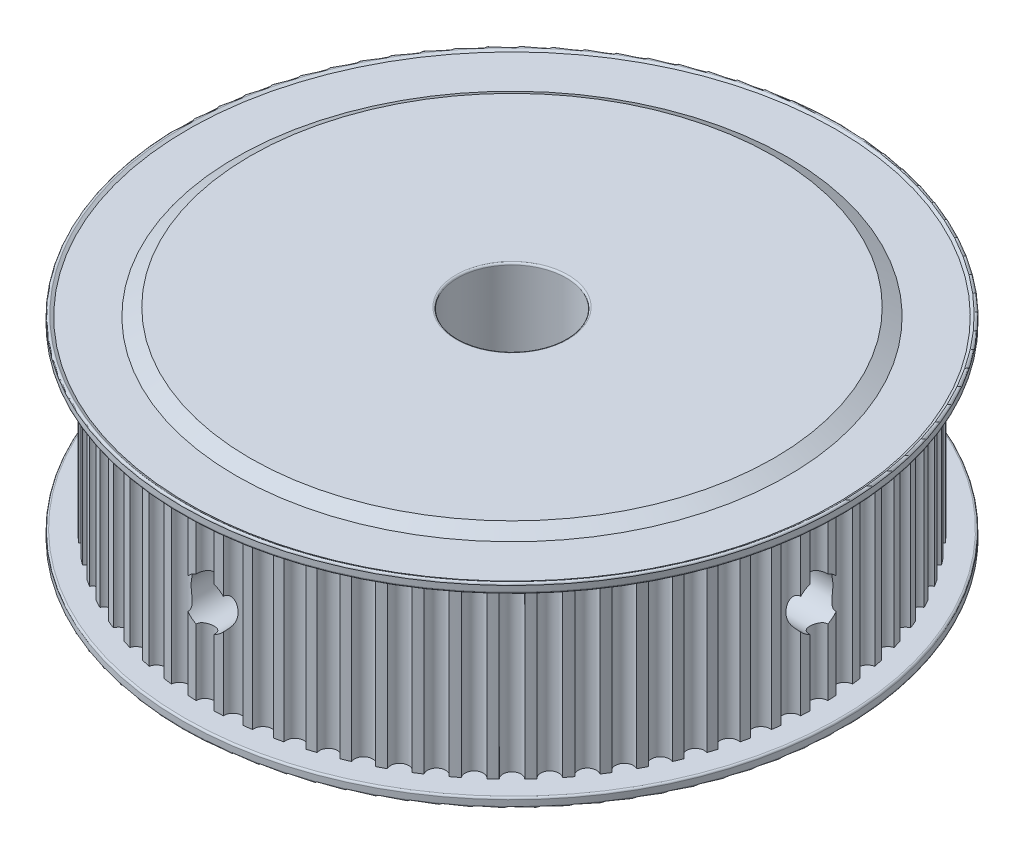
from build123d import *

# Parameters (mm, degrees)
FILLET1_R            = 0.2
BOSS_EXTRUDE1_DEPTH  = 19.5
FILLET1_OF_MIRROR1_R = 0.2
SKETCH4_R            = 2.6
CUT_EXTRUDE1_DEPTH   = 36.5
SKETCH5_R            = 2.6
CUT_EXTRUDE2_DEPTH   = 36.5
SKETCH3_R            = 6
CUT_EXTRUDE3_DEPTH   = 24
FILLET2_R            = 0.2
SCALE2_SCALE         = 0.2
SCALE4_SCALE         = 2


with BuildPart() as part:
    # Sketch1 → Revolve1 (revolve)
    with BuildSketch(Plane.XY):
        Polygon((0, 0), (0, 1.75), (36.5, 1.75), (36.5, 0.55), (35.893782217, 0.9), (30.558845727, 0.9), (29, 0), align=None)
    revolve1 = revolve(axis=Axis((0, 0, 0), (0, 1, 0)))

    # Fillet1
    fillet1_edges = [part.edges().sort_by_distance(p)[0] for p in [
        (-36.5, 0.55, 0),
        (-36.5, 1.75, 0),
    ]]
    fillet(fillet1_edges, radius=FILLET1_R)

    # Sketch2 → Boss-Extrude1 (add)
    with BuildSketch(Plane(origin=(0, 1.75, 0), x_dir=(1, 0, 0), z_dir=(0, 1, 0))):
        with BuildLine():
            ThreePointArc((1.965926579, 33.943116131), (1.48305917, 33.967639534), (0.999891863, 33.985294118))
            ThreePointArc((0.999891863, 33.985294118), (0, 33), (-0.999891863, 33.985294118))
            ThreePointArc((-0.999891863, 33.985294118), (-1.48305917, 33.967639534), (-1.965926579, 33.943116131))
            ThreePointArc((-1.965926579, 33.943116131), (-2.876139511, 32.874425037), (-3.958100524, 33.768823495))
            ThreePointArc((-3.958100524, 33.768823495), (-4.437890535, 33.709125287), (-4.916783132, 33.642610535))
            ThreePointArc((-4.916783132, 33.642610535), (-5.730389863, 32.498655849), (-6.88618565, 33.295351736))
            ThreePointArc((-6.88618565, 33.295351736), (-7.358946874, 33.194064242), (-7.830219997, 33.086064359))
            ThreePointArc((-7.830219997, 33.086064359), (-8.541028488, 31.875552268), (-9.761862745, 32.568482245))
            ThreePointArc((-9.761862745, 32.568482245), (-10.223997183, 32.426376325), (-10.68406416, 32.277713256))
            ThreePointArc((-10.68406416, 32.277713256), (-11.28666473, 31.009856486), (-12.56324617, 31.593746939))
            ThreePointArc((-12.56324617, 31.593746939), (-13.0112367, 31.411904105), (-13.456596143, 31.223709264))
            ThreePointArc((-13.456596143, 31.223709264), (-13.946402637, 29.908156972), (-15.269015706, 30.378564143))
            ThreePointArc((-15.269015706, 30.378564143), (-15.69945285, 30.158368328), (-16.126715305, 29.932073992))
            ThreePointArc((-16.126715305, 29.932073992), (-16.5, 28.578838325), (-17.858578813, 28.93218213))
            ThreePointArc((-17.858578813, 28.93218213), (-18.268186684, 28.675309158), (-18.674100425, 28.412637564))
            ThreePointArc((-18.674100425, 28.412637564), (-18.9280224, 27.032017462), (-20.312227352, 27.265608741))
            ThreePointArc((-20.312227352, 27.265608741), (-20.697888586, 26.97401357), (-21.079364365, 26.676963807))
            ThreePointArc((-21.079364365, 26.676963807), (-21.21199112, 25.279466623), (-22.611287575, 25.391527606))
            ThreePointArc((-22.611287575, 25.391527606), (-22.970067059, 25.067429452), (-23.324201615, 24.738262248))
            ThreePointArc((-23.324201615, 24.738262248), (-23.334523779, 23.334523779), (-24.738262248, 23.324201615))
            ThreePointArc((-24.738262248, 23.324201615), (-25.067429452, 22.970067059), (-25.391527606, 22.611287575))
            ThreePointArc((-25.391527606, 22.611287575), (-25.279466623, 21.21199112), (-26.676963807, 21.079364365))
            ThreePointArc((-26.676963807, 21.079364365), (-26.97401357, 20.697888586), (-27.265608741, 20.312227352))
            ThreePointArc((-27.265608741, 20.312227352), (-27.032017462, 18.9280224), (-28.412637564, 18.674100425))
            ThreePointArc((-28.412637564, 18.674100425), (-28.675309158, 18.268186684), (-28.93218213, 17.858578813))
            ThreePointArc((-28.93218213, 17.858578813), (-28.578838325, 16.5), (-29.932073992, 16.126715305))
            ThreePointArc((-29.932073992, 16.126715305), (-30.158368328, 15.69945285), (-30.378564143, 15.269015706))
            ThreePointArc((-30.378564143, 15.269015706), (-29.908156972, 13.946402637), (-31.223709264, 13.456596143))
            ThreePointArc((-31.223709264, 13.456596143), (-31.411904105, 13.0112367), (-31.593746939, 12.56324617))
            ThreePointArc((-31.593746939, 12.56324617), (-31.009856486, 11.28666473), (-32.277713256, 10.68406416))
            ThreePointArc((-32.277713256, 10.68406416), (-32.426376325, 10.223997183), (-32.568482245, 9.761862745))
            ThreePointArc((-32.568482245, 9.761862745), (-31.875552268, 8.541028488), (-33.086064359, 7.830219997))
            ThreePointArc((-33.086064359, 7.830219997), (-33.194064242, 7.358946874), (-33.295351736, 6.88618565))
            ThreePointArc((-33.295351736, 6.88618565), (-32.498655849, 5.730389863), (-33.642610535, 4.916783132))
            ThreePointArc((-33.642610535, 4.916783132), (-33.709125287, 4.437890535), (-33.768823495, 3.958100524))
            ThreePointArc((-33.768823495, 3.958100524), (-32.874425037, 2.876139511), (-33.943116131, 1.965926579))
            ThreePointArc((-33.943116131, 1.965926579), (-33.967639534, 1.48305917), (-33.985294118, 0.999891863))
            ThreePointArc((-33.985294118, 0.999891863), (-33, 0), (-33.985294118, -0.999891863))
            ThreePointArc((-33.985294118, -0.999891863), (-33.967639534, -1.48305917), (-33.943116131, -1.965926579))
            ThreePointArc((-33.943116131, -1.965926579), (-32.874425037, -2.876139511), (-33.768823495, -3.958100524))
            ThreePointArc((-33.768823495, -3.958100524), (-33.709125287, -4.437890535), (-33.642610535, -4.916783132))
            ThreePointArc((-33.642610535, -4.916783132), (-32.498655849, -5.730389863), (-33.295351736, -6.88618565))
            ThreePointArc((-33.295351736, -6.88618565), (-33.194064242, -7.358946874), (-33.086064359, -7.830219997))
            ThreePointArc((-33.086064359, -7.830219997), (-31.875552268, -8.541028488), (-32.568482245, -9.761862745))
            ThreePointArc((-32.568482245, -9.761862745), (-32.426376325, -10.223997183), (-32.277713256, -10.68406416))
            ThreePointArc((-32.277713256, -10.68406416), (-31.009856486, -11.28666473), (-31.593746939, -12.56324617))
            ThreePointArc((-31.593746939, -12.56324617), (-31.411904105, -13.0112367), (-31.223709264, -13.456596143))
            ThreePointArc((-31.223709264, -13.456596143), (-29.908156972, -13.946402637), (-30.378564143, -15.269015706))
            ThreePointArc((-30.378564143, -15.269015706), (-30.158368328, -15.69945285), (-29.932073992, -16.126715305))
            ThreePointArc((-29.932073992, -16.126715305), (-28.578838325, -16.5), (-28.93218213, -17.858578813))
            ThreePointArc((-28.93218213, -17.858578813), (-28.675309158, -18.268186684), (-28.412637564, -18.674100425))
            ThreePointArc((-28.412637564, -18.674100425), (-27.032017462, -18.9280224), (-27.265608741, -20.312227352))
            ThreePointArc((-27.265608741, -20.312227352), (-26.97401357, -20.697888586), (-26.676963807, -21.079364365))
            ThreePointArc((-26.676963807, -21.079364365), (-25.279466623, -21.21199112), (-25.391527606, -22.611287575))
            ThreePointArc((-25.391527606, -22.611287575), (-25.067429452, -22.970067059), (-24.738262248, -23.324201615))
            ThreePointArc((-24.738262248, -23.324201615), (-23.334523779, -23.334523779), (-23.324201615, -24.738262248))
            ThreePointArc((-23.324201615, -24.738262248), (-22.970067059, -25.067429452), (-22.611287575, -25.391527606))
            ThreePointArc((-22.611287575, -25.391527606), (-21.21199112, -25.279466623), (-21.079364365, -26.676963807))
            ThreePointArc((-21.079364365, -26.676963807), (-20.697888586, -26.97401357), (-20.312227352, -27.265608741))
            ThreePointArc((-20.312227352, -27.265608741), (-18.9280224, -27.032017462), (-18.674100425, -28.412637564))
            ThreePointArc((-18.674100425, -28.412637564), (-18.268186684, -28.675309158), (-17.858578813, -28.93218213))
            ThreePointArc((-17.858578813, -28.93218213), (-16.5, -28.578838325), (-16.126715305, -29.932073992))
            ThreePointArc((-16.126715305, -29.932073992), (-15.69945285, -30.158368328), (-15.269015706, -30.378564143))
            ThreePointArc((-15.269015706, -30.378564143), (-13.946402637, -29.908156972), (-13.456596143, -31.223709264))
            ThreePointArc((-13.456596143, -31.223709264), (-13.0112367, -31.411904105), (-12.56324617, -31.593746939))
            ThreePointArc((-12.56324617, -31.593746939), (-11.28666473, -31.009856486), (-10.68406416, -32.277713256))
            ThreePointArc((-10.68406416, -32.277713256), (-10.223997183, -32.426376325), (-9.761862745, -32.568482245))
            ThreePointArc((-9.761862745, -32.568482245), (-8.541028488, -31.875552268), (-7.830219997, -33.086064359))
            ThreePointArc((-7.830219997, -33.086064359), (-7.358946874, -33.194064242), (-6.88618565, -33.295351736))
            ThreePointArc((-6.88618565, -33.295351736), (-5.730389863, -32.498655849), (-4.916783132, -33.642610535))
            ThreePointArc((-4.916783132, -33.642610535), (-4.437890535, -33.709125287), (-3.958100524, -33.768823495))
            ThreePointArc((-3.958100524, -33.768823495), (-2.876139511, -32.874425037), (-1.965926579, -33.943116131))
            ThreePointArc((-1.965926579, -33.943116131), (-1.48305917, -33.967639534), (-0.999891863, -33.985294118))
            ThreePointArc((-0.999891863, -33.985294118), (0, -33), (0.999891863, -33.985294118))
            ThreePointArc((0.999891863, -33.985294118), (1.48305917, -33.967639534), (1.965926579, -33.943116131))
            ThreePointArc((1.965926579, -33.943116131), (2.876139511, -32.874425037), (3.958100524, -33.768823495))
            ThreePointArc((3.958100524, -33.768823495), (4.437890535, -33.709125287), (4.916783132, -33.642610535))
            ThreePointArc((4.916783132, -33.642610535), (5.730389863, -32.498655849), (6.88618565, -33.295351736))
            ThreePointArc((6.88618565, -33.295351736), (7.358946874, -33.194064242), (7.830219997, -33.086064359))
            ThreePointArc((7.830219997, -33.086064359), (8.541028488, -31.875552268), (9.761862745, -32.568482245))
            ThreePointArc((9.761862745, -32.568482245), (10.223997183, -32.426376325), (10.68406416, -32.277713256))
            ThreePointArc((10.68406416, -32.277713256), (11.28666473, -31.009856486), (12.56324617, -31.593746939))
            ThreePointArc((12.56324617, -31.593746939), (13.0112367, -31.411904105), (13.456596143, -31.223709264))
            ThreePointArc((13.456596143, -31.223709264), (13.946402637, -29.908156972), (15.269015706, -30.378564143))
            ThreePointArc((15.269015706, -30.378564143), (15.69945285, -30.158368328), (16.126715305, -29.932073992))
            ThreePointArc((16.126715305, -29.932073992), (16.5, -28.578838325), (17.858578813, -28.93218213))
            ThreePointArc((17.858578813, -28.93218213), (18.268186684, -28.675309158), (18.674100425, -28.412637564))
            ThreePointArc((18.674100425, -28.412637564), (18.9280224, -27.032017462), (20.312227352, -27.265608741))
            ThreePointArc((20.312227352, -27.265608741), (20.697888586, -26.97401357), (21.079364365, -26.676963807))
            ThreePointArc((21.079364365, -26.676963807), (21.21199112, -25.279466623), (22.611287575, -25.391527606))
            ThreePointArc((22.611287575, -25.391527606), (22.970067059, -25.067429452), (23.324201615, -24.738262248))
            ThreePointArc((23.324201615, -24.738262248), (23.334523779, -23.334523779), (24.738262248, -23.324201615))
            ThreePointArc((24.738262248, -23.324201615), (25.067429452, -22.970067059), (25.391527606, -22.611287575))
            ThreePointArc((25.391527606, -22.611287575), (25.279466623, -21.21199112), (26.676963807, -21.079364365))
            ThreePointArc((26.676963807, -21.079364365), (26.97401357, -20.697888586), (27.265608741, -20.312227352))
            ThreePointArc((27.265608741, -20.312227352), (27.032017462, -18.9280224), (28.412637564, -18.674100425))
            ThreePointArc((28.412637564, -18.674100425), (28.675309158, -18.268186684), (28.93218213, -17.858578813))
            ThreePointArc((28.93218213, -17.858578813), (28.578838325, -16.5), (29.932073992, -16.126715305))
            ThreePointArc((29.932073992, -16.126715305), (30.158368328, -15.69945285), (30.378564143, -15.269015706))
            ThreePointArc((30.378564143, -15.269015706), (29.908156972, -13.946402637), (31.223709264, -13.456596143))
            ThreePointArc((31.223709264, -13.456596143), (31.411904105, -13.0112367), (31.593746939, -12.56324617))
            ThreePointArc((31.593746939, -12.56324617), (31.009856486, -11.28666473), (32.277713256, -10.68406416))
            ThreePointArc((32.277713256, -10.68406416), (32.426376325, -10.223997183), (32.568482245, -9.761862745))
            ThreePointArc((32.568482245, -9.761862745), (31.875552268, -8.541028488), (33.086064359, -7.830219997))
            ThreePointArc((33.086064359, -7.830219997), (33.194064242, -7.358946874), (33.295351736, -6.88618565))
            ThreePointArc((33.295351736, -6.88618565), (32.498655849, -5.730389863), (33.642610535, -4.916783132))
            ThreePointArc((33.642610535, -4.916783132), (33.709125287, -4.437890535), (33.768823495, -3.958100524))
            ThreePointArc((33.768823495, -3.958100524), (32.874425037, -2.876139511), (33.943116131, -1.965926579))
            ThreePointArc((33.943116131, -1.965926579), (33.967639534, -1.48305917), (33.985294118, -0.999891863))
            ThreePointArc((33.985294118, -0.999891863), (33, 0), (33.985294118, 0.999891863))
            ThreePointArc((33.985294118, 0.999891863), (33.967639534, 1.48305917), (33.943116131, 1.965926579))
            ThreePointArc((33.943116131, 1.965926579), (32.874425037, 2.876139511), (33.768823495, 3.958100524))
            ThreePointArc((33.768823495, 3.958100524), (33.709125287, 4.437890535), (33.642610535, 4.916783132))
            ThreePointArc((33.642610535, 4.916783132), (32.498655849, 5.730389863), (33.295351736, 6.88618565))
            ThreePointArc((33.295351736, 6.88618565), (33.194064242, 7.358946874), (33.086064359, 7.830219997))
            ThreePointArc((33.086064359, 7.830219997), (31.875552268, 8.541028488), (32.568482245, 9.761862745))
            ThreePointArc((32.568482245, 9.761862745), (32.426376325, 10.223997183), (32.277713256, 10.68406416))
            ThreePointArc((32.277713256, 10.68406416), (31.009856486, 11.28666473), (31.593746939, 12.56324617))
            ThreePointArc((31.593746939, 12.56324617), (31.411904105, 13.0112367), (31.223709264, 13.456596143))
            ThreePointArc((31.223709264, 13.456596143), (29.908156972, 13.946402637), (30.378564143, 15.269015706))
            ThreePointArc((30.378564143, 15.269015706), (30.158368328, 15.69945285), (29.932073992, 16.126715305))
            ThreePointArc((29.932073992, 16.126715305), (28.578838325, 16.5), (28.93218213, 17.858578813))
            ThreePointArc((28.93218213, 17.858578813), (28.675309158, 18.268186684), (28.412637564, 18.674100425))
            ThreePointArc((28.412637564, 18.674100425), (27.032017462, 18.9280224), (27.265608741, 20.312227352))
            ThreePointArc((27.265608741, 20.312227352), (26.97401357, 20.697888586), (26.676963807, 21.079364365))
            ThreePointArc((26.676963807, 21.079364365), (25.279466623, 21.21199112), (25.391527606, 22.611287575))
            ThreePointArc((25.391527606, 22.611287575), (25.067429452, 22.970067059), (24.738262248, 23.324201615))
            ThreePointArc((24.738262248, 23.324201615), (23.334523779, 23.334523779), (23.324201615, 24.738262248))
            ThreePointArc((23.324201615, 24.738262248), (22.970067059, 25.067429452), (22.611287575, 25.391527606))
            ThreePointArc((22.611287575, 25.391527606), (21.21199112, 25.279466623), (21.079364365, 26.676963807))
            ThreePointArc((21.079364365, 26.676963807), (20.697888586, 26.97401357), (20.312227352, 27.265608741))
            ThreePointArc((20.312227352, 27.265608741), (18.9280224, 27.032017462), (18.674100425, 28.412637564))
            ThreePointArc((18.674100425, 28.412637564), (18.268186684, 28.675309158), (17.858578813, 28.93218213))
            ThreePointArc((17.858578813, 28.93218213), (16.5, 28.578838325), (16.126715305, 29.932073992))
            ThreePointArc((16.126715305, 29.932073992), (15.69945285, 30.158368328), (15.269015706, 30.378564143))
            ThreePointArc((15.269015706, 30.378564143), (13.946402637, 29.908156972), (13.456596143, 31.223709264))
            ThreePointArc((13.456596143, 31.223709264), (13.0112367, 31.411904105), (12.56324617, 31.593746939))
            ThreePointArc((12.56324617, 31.593746939), (11.28666473, 31.009856486), (10.68406416, 32.277713256))
            ThreePointArc((10.68406416, 32.277713256), (10.223997183, 32.426376325), (9.761862745, 32.568482245))
            ThreePointArc((9.761862745, 32.568482245), (8.541028488, 31.875552268), (7.830219997, 33.086064359))
            ThreePointArc((7.830219997, 33.086064359), (7.358946874, 33.194064242), (6.88618565, 33.295351736))
            ThreePointArc((6.88618565, 33.295351736), (5.730389863, 32.498655849), (4.916783132, 33.642610535))
            ThreePointArc((4.916783132, 33.642610535), (4.437890535, 33.709125287), (3.958100524, 33.768823495))
            ThreePointArc((3.958100524, 33.768823495), (2.876139511, 32.874425037), (1.965926579, 33.943116131))
        make_face()
    extrude(amount=BOSS_EXTRUDE1_DEPTH)

    # Mirror1: Revolve1 across plane
    add(revolve1.mirror(Plane.ZX.offset(11.5)))

    # Fillet1 of Mirror1
    fillet1_of_mirror1_edges = [part.edges().sort_by_distance(p)[0] for p in [
        (-36.5, 22.45, 0),
        (-36.5, 21.25, 0),
    ]]
    fillet(fillet1_of_mirror1_edges, radius=FILLET1_OF_MIRROR1_R)

    # Sketch4 → Cut-Extrude1 (cut)
    with BuildSketch(Plane.XY):
        with Locations((0, 11.5)):
            Circle(SKETCH4_R)
    extrude(amount=CUT_EXTRUDE1_DEPTH, mode=Mode.SUBTRACT)

    # Sketch5 → Cut-Extrude2 (cut)
    with BuildSketch(Plane(origin=(0, 0, 0), x_dir=(0, 0, -1), z_dir=(1, 0, 0))):
        with Locations((0, 11.5)):
            Circle(SKETCH5_R)
    extrude(amount=CUT_EXTRUDE2_DEPTH, mode=Mode.SUBTRACT)

    # Sketch3 → Cut-Extrude3 (cut, through all)
    with BuildSketch(Plane(origin=(0, 23, 0), x_dir=(1, 0, 0), z_dir=(0, 1, 0))):
        Circle(SKETCH3_R)
    extrude(amount=-CUT_EXTRUDE3_DEPTH, mode=Mode.SUBTRACT)

    # Fillet2
    fillet2_edges = [part.edges().sort_by_distance(p)[0] for p in [
        (-6, 0, 0),
        (-6, 23, 0),
    ]]
    fillet(fillet2_edges, radius=FILLET2_R)


with BuildPart() as part_1:
    # Scale2: scaled about (-0.150087732, 11.500000022, -0.150087739)
    add(part.part.scale(SCALE2_SCALE).moved(Location((-0.120070186, 9.200000018, -0.120070191))))


with BuildPart() as part_2:
    # Scale4: scaled about (-0.150087732, 11.500000022, -0.150087739)
    add(part_1.part.scale(SCALE4_SCALE).moved(Location((0.150087732, -11.500000022, 0.150087739))))


solid = part_2.part
